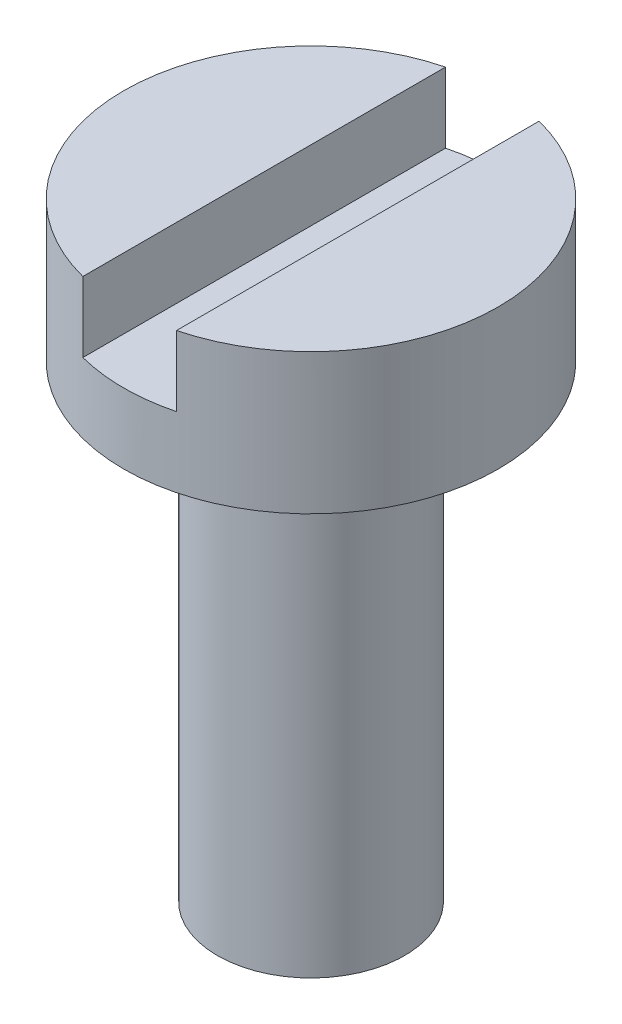
from build123d import *

# Parameters (mm, degrees)
SKETCH1_R          = 4
EXTRUDE1_DEPTH     = 3
CUT_EXTRUDE1_DEPTH = 1.5
SKETCH3_R          = 2
EXTRUDE2_DEPTH     = 10


with BuildPart() as part:
    # Sketch1 → Extrude1 (new body)
    with BuildSketch(Plane(origin=(0, 0, 0), x_dir=(1, 0, 0), z_dir=(0, 1, 0))):
        with Locations(Location((0, 0, 0), (0, 0, 270))):  # turned: the seam where the file's is
            Circle(SKETCH1_R)
    extrude(amount=EXTRUDE1_DEPTH)

    # Sketch2 → Cut-Extrude1 (cut)
    with BuildSketch(Plane(origin=(0, 3, 0), x_dir=(-1, 0, 0), z_dir=(0, 1, 0))):
        Polygon((0, 4.401224563), (-1, 4.401224563), (-1, -5.078336035), (1, -5.078336035), (1, 4.401224563), align=None)
    extrude(amount=-CUT_EXTRUDE1_DEPTH, mode=Mode.SUBTRACT)

    # Sketch3 → Extrude2 (add)
    with BuildSketch(Plane.XZ):
        with Locations(Location((0, 0, 0), (0, 0, 90))):  # turned: the seam where the file's is
            Circle(SKETCH3_R)
    extrude(amount=EXTRUDE2_DEPTH)


solid = part.part
